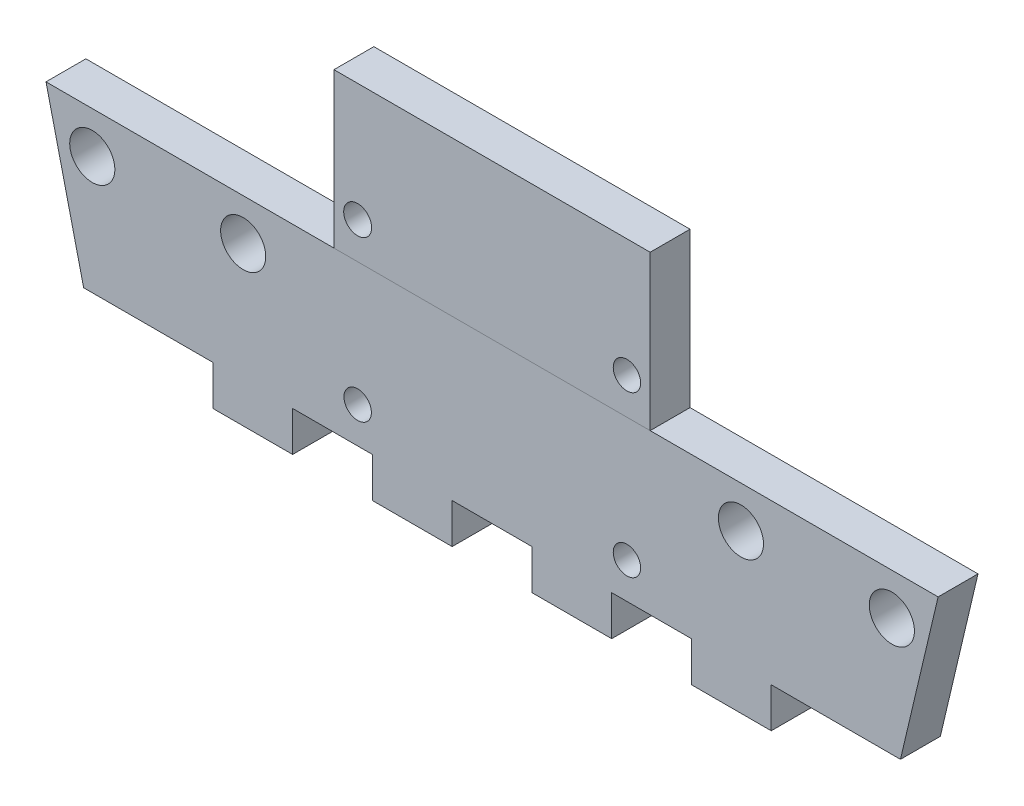
from build123d import *

# Parameters (mm, degrees)
SKETCH1_W           = 6.35
SKETCH1_H           = 3.175
BOSS_EXTRUDE1_DEPTH = 3.175
SKETCH2_W           = 65.60314911
SKETCH2_H           = 5.913175186
CUT_EXTRUDE2_DEPTH  = 10
SKETCH3_W           = 25.1714
SKETCH3_H           = 12.3
BOSS_EXTRUDE2_DEPTH = 3.175
SKETCH6_R           = 1.0922
SKETCH6_R_2         = 1.112076506
CUT_EXTRUDE3_DEPTH  = 3.175
SKETCH8_R           = 1.79705
CUT_EXTRUDE4_DEPTH  = 3.175


with BuildPart() as part:
    # Sketch1 → Boss-Extrude1 (new body)
    with BuildSketch(Plane.XY):
        Polygon((10.287, 0), (0, 0), (0, -12.7), (10.287, -12.7), (16.637, -12.7), (22.987, -12.7), (29.337, -12.7), (35.687, -12.7), (42.037, -12.7), (48.387, -12.7), (54.737, -12.7), (65.024, -12.7), (65.024, 0), (54.737, 0), (48.387, 0), (42.037, 0), (35.687, 0), (29.337, 0), (22.987, 0), (16.637, 0), align=None)
        with Locations((13.462, 1.5875)):
            Rectangle(SKETCH1_W, SKETCH1_H)
        with Locations((26.162, 1.5875)):
            Rectangle(SKETCH1_W, SKETCH1_H)
        with Locations((51.562, 1.5875)):
            Rectangle(SKETCH1_W, SKETCH1_H)
        with Locations((51.562, -14.2875)):
            Rectangle(SKETCH1_W, SKETCH1_H)
        with Locations((38.862, -14.2875)):
            Rectangle(SKETCH1_W, SKETCH1_H)
        with Locations((26.162, -14.2875)):
            Rectangle(SKETCH1_W, SKETCH1_H)
        with Locations((13.462, -14.2875)):
            Rectangle(SKETCH1_W, SKETCH1_H)
        Polygon((-2.9972, 0), (0, 0), (0, -12.7), align=None)
        Polygon((65.024, 0), (65.024, -12.7), (68.0212, 0), align=None)
        with Locations((38.862, 1.5875)):
            Rectangle(SKETCH1_W, SKETCH1_H)
    extrude(amount=BOSS_EXTRUDE1_DEPTH)

    # Sketch2 → Cut-Extrude2 (cut)
    with BuildSketch(Plane.XY.offset(3.175)):
        with Locations((32.801574555, 2.956587593)):
            Rectangle(SKETCH2_W, SKETCH2_H)
    extrude(amount=-CUT_EXTRUDE2_DEPTH, mode=Mode.SUBTRACT)


with BuildPart() as body_2:
    # Sketch3 → Boss-Extrude2 (new body)
    with BuildSketch(Plane.XY.offset(3.175)):
        with Locations((32.512, 6.15)):
            Rectangle(SKETCH3_W, SKETCH3_H)
    extrude(amount=-BOSS_EXTRUDE2_DEPTH)


with BuildPart() as cut_extrude3_tool:
    # Sketch6 → Cut-Extrude3 (new body)
    with BuildSketch(Plane(origin=(0, 0, 0), x_dir=(-1, 0, 0), z_dir=(0, 0, -1))):
        with Locations((-43.25056982, 2.902)):
            Circle(SKETCH6_R)
        with Locations((-21.81296982, 2.902)):
            Circle(SKETCH6_R_2)
        with Locations((-21.81296982, -9.8488)):
            Circle(SKETCH6_R)
        with Locations((-43.25056982, -9.8488)):
            Circle(SKETCH6_R)
    extrude(amount=-CUT_EXTRUDE3_DEPTH)


with BuildPart() as part_1:
    add(part.part)

    # Cut-Extrude3: cut by cut_extrude3_tool
    add(cut_extrude3_tool.part, mode=Mode.SUBTRACT)

    # Sketch8 → Cut-Extrude4 (cut)
    with BuildSketch(Plane(origin=(0, 0, 0), x_dir=(-1, 0, 0), z_dir=(0, 0, -1))):
        with Locations((-64.3382, -3.302)):
            Circle(SKETCH8_R)
        with Locations((-52.324, -3.302)):
            Circle(SKETCH8_R)
        with Locations((-12.7, -3.302)):
            Circle(SKETCH8_R)
        with Locations((-0.6858, -3.302)):
            Circle(SKETCH8_R)
    extrude(amount=-CUT_EXTRUDE4_DEPTH, mode=Mode.SUBTRACT)


with BuildPart() as body_2_1:
    add(body_2.part)

    # Cut-Extrude3: cut by cut_extrude3_tool
    add(cut_extrude3_tool.part, mode=Mode.SUBTRACT)


solid = Compound([part_1.part, body_2_1.part])
